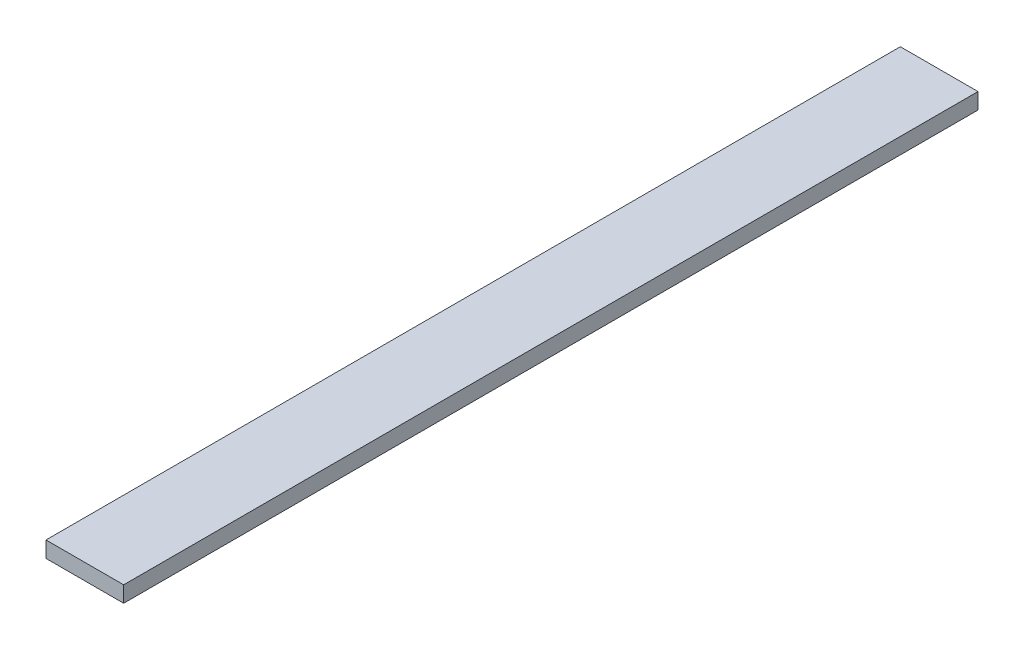
from build123d import *

# Parameters (mm, degrees)
SKETCH1_W           = 23.090909091
SKETCH1_H           = 254
BOSS_EXTRUDE1_DEPTH = 4.7625


with BuildPart() as part:
    # Sketch1 → Boss-Extrude1 (new body)
    with BuildSketch(Plane(origin=(0, 0, 0), x_dir=(1, 0, 0), z_dir=(0, 1, 0))):
        with Locations((11.545454546, -127)):
            Rectangle(SKETCH1_W, SKETCH1_H)
    extrude(amount=BOSS_EXTRUDE1_DEPTH)


solid = part.part
